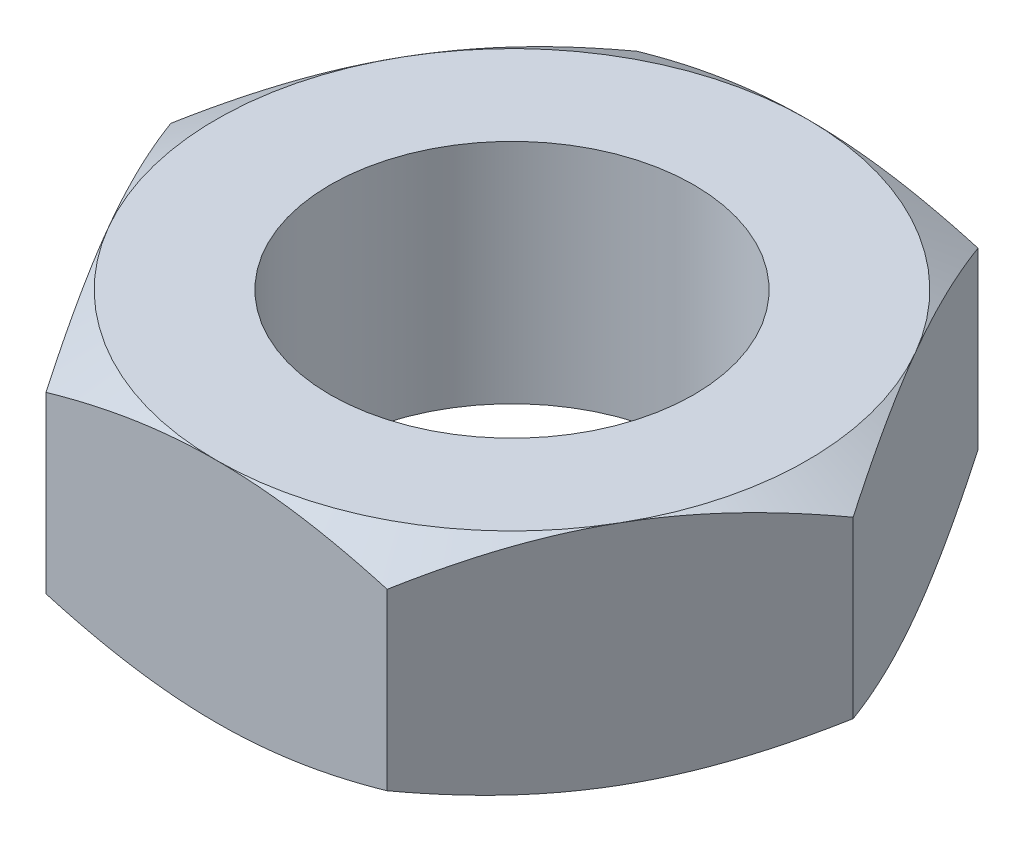
from build123d import *

# Parameters (mm, degrees)
ESQUISSE2_OUTSIDE_W     = 25.68
ESQUISSE2_OUTSIDE_H     = 25.68
ENL_V_MAT_EXTRU_1_DEPTH = 5


with BuildPart() as part:
    # Esquisse1 → Base-Révolution (revolve)
    with BuildSketch(Plane.XY, mode=Mode.PRIVATE) as base_r_volution_sk:
        Polygon((4, 5), (6.5, 5), (9.192388155, 3.445548946), (9.192388155, 1.554451054), (6.5, 0), (4, 0), align=None)
    revolve(base_r_volution_sk.sketch.rotate(Axis((0, 2.4, 0), (0, -1, 0)), 90), axis=Axis((0, 2.4, 0), (0, -1, 0)))  # turned: the seam where the file's is

    # Esquisse2 outside → Enlèv. mat.-Extru.1 (cut)
    with BuildSketch(Plane(origin=(0, 0, 0), x_dir=(1, 0, 0), z_dir=(0, 1, 0))):
        Rectangle(ESQUISSE2_OUTSIDE_W, ESQUISSE2_OUTSIDE_H)
        Polygon((-3.75277675, -6.5), (3.75277675, -6.5), (7.505553499, 0), (3.75277675, 6.5), (-3.75277675, 6.5), (-7.505553499, 0), align=None, mode=Mode.SUBTRACT)
    extrude(amount=ENL_V_MAT_EXTRU_1_DEPTH, mode=Mode.SUBTRACT)


solid = part.part
